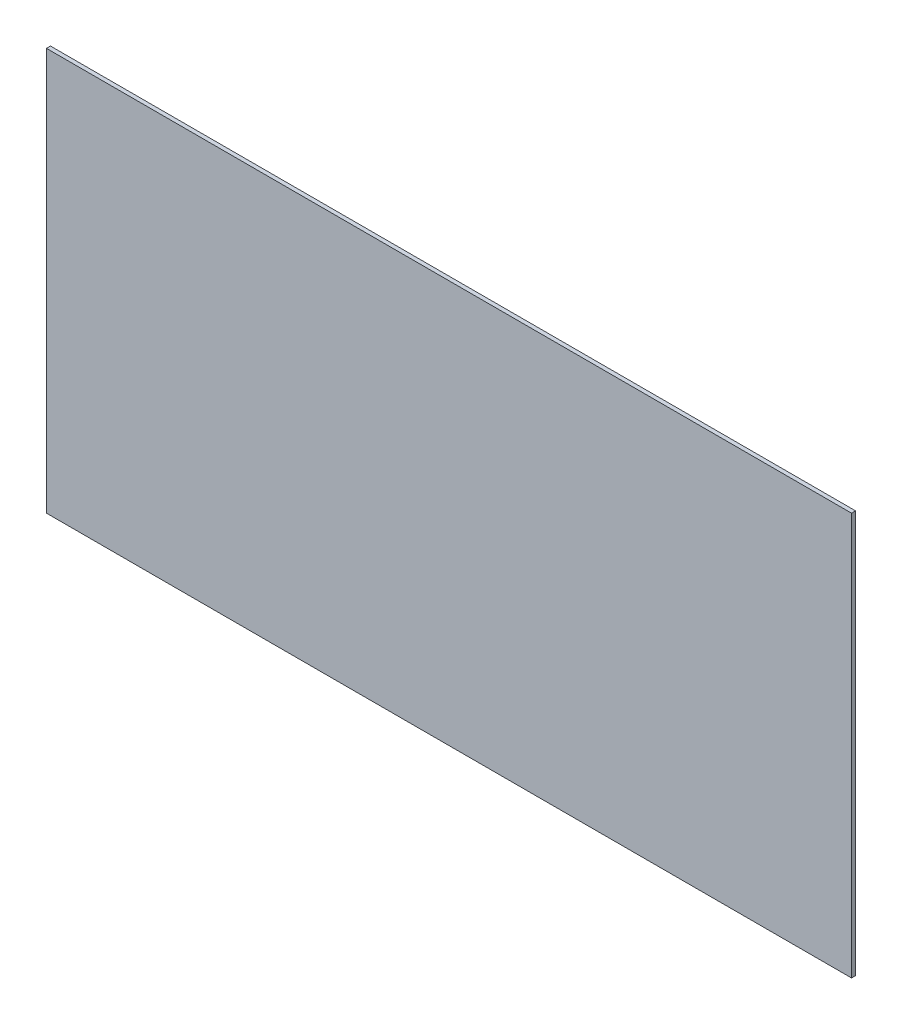
from build123d import *

# Parameters (mm, degrees)
SKETCH1_W           = 2000
SKETCH1_H           = 1000
BOSS_EXTRUDE1_DEPTH = 10


with BuildPart() as part:
    # Sketch1 → Boss-Extrude1 (new body)
    with BuildSketch(Plane.XY):
        with Locations((1000, 500)):
            Rectangle(SKETCH1_W, SKETCH1_H)
    extrude(amount=-BOSS_EXTRUDE1_DEPTH)


solid = part.part
